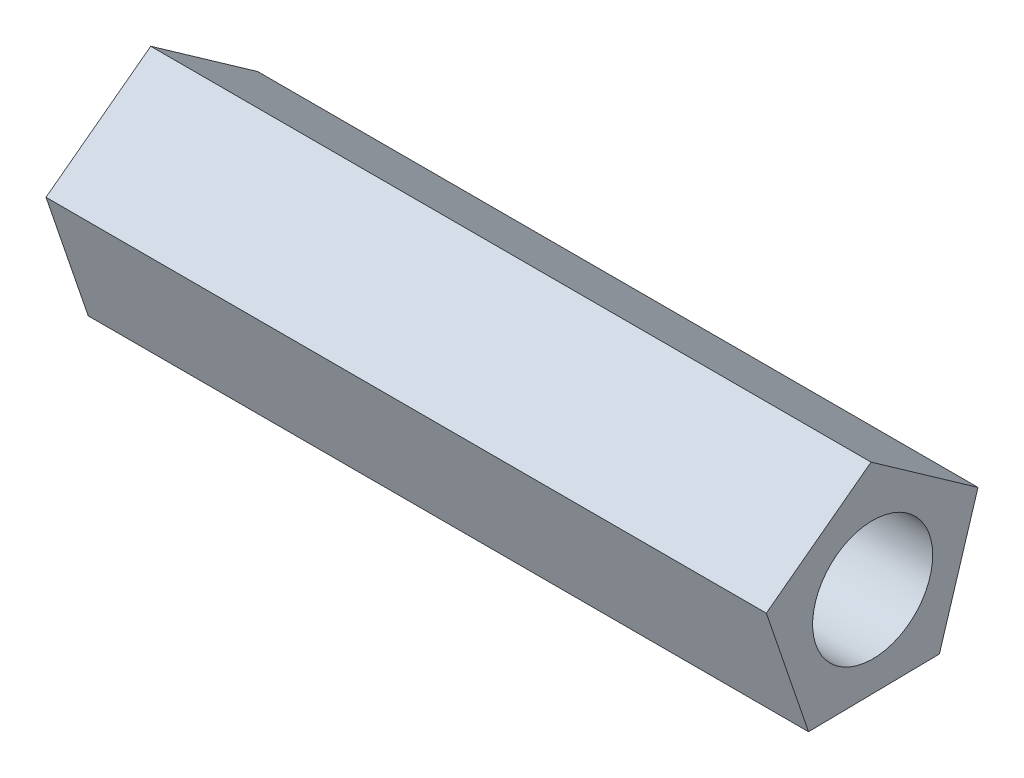
from build123d import *

# Parameters (mm, degrees)
SKETCH6_R           = 5
BOSS_EXTRUDE2_DEPTH = 30


with BuildPart() as part:
    # Sketch6 → Boss-Extrude2 (new body, symmetric)
    with BuildSketch(Plane(origin=(0, 0, 0), x_dir=(0, 0, -1), z_dir=(1, 0, 0))):
        Polygon((5.557116467, -7.420297103), (8.774365341, 2.99213392), (-0.134260457, 9.269537565), (-8.857342867, 2.736755355), (-5.339878485, -7.578129736), align=None)
        Circle(SKETCH6_R, mode=Mode.SUBTRACT)
    extrude(amount=BOSS_EXTRUDE2_DEPTH, both=True)


solid = part.part
